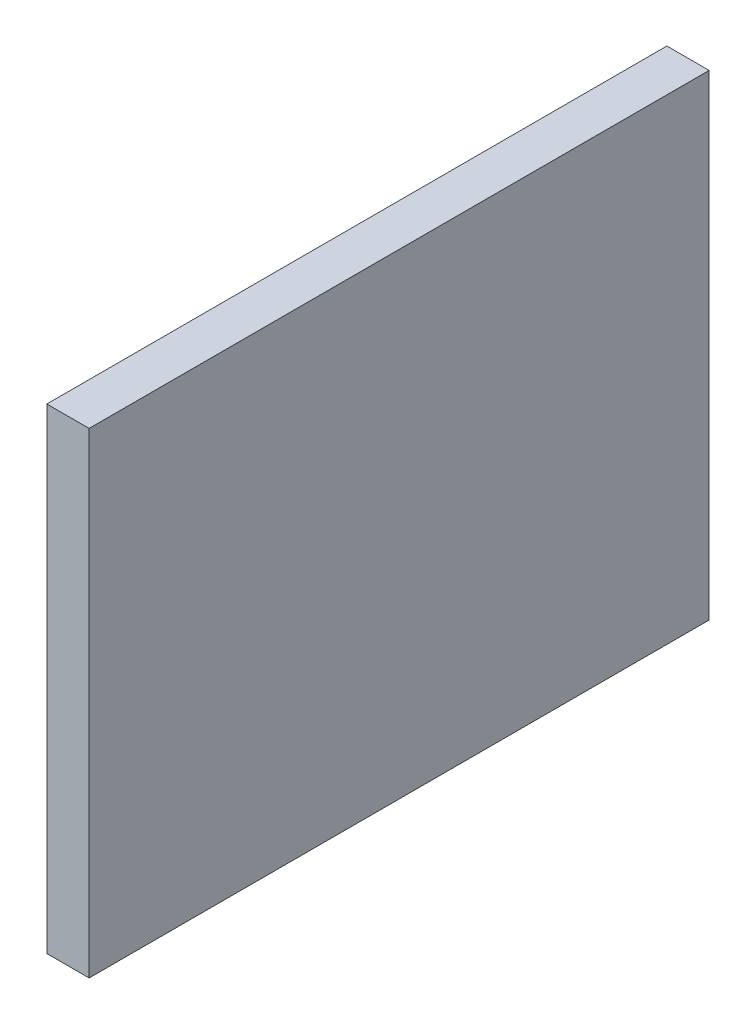
from build123d import *

# Parameters (mm, degrees)
SKETCH1_W           = 44
SKETCH1_H           = 33.775924272
BOSS_EXTRUDE1_DEPTH = 3


with BuildPart() as part:
    # Sketch1 → Boss-Extrude1 (new body)
    with BuildSketch(Plane(origin=(0, 0, 0), x_dir=(0, 0, -1), z_dir=(1, 0, 0))):
        with Locations((19.038383019, -39.825701439)):
            Rectangle(SKETCH1_W, SKETCH1_H)
    extrude(amount=BOSS_EXTRUDE1_DEPTH)


solid = part.part
